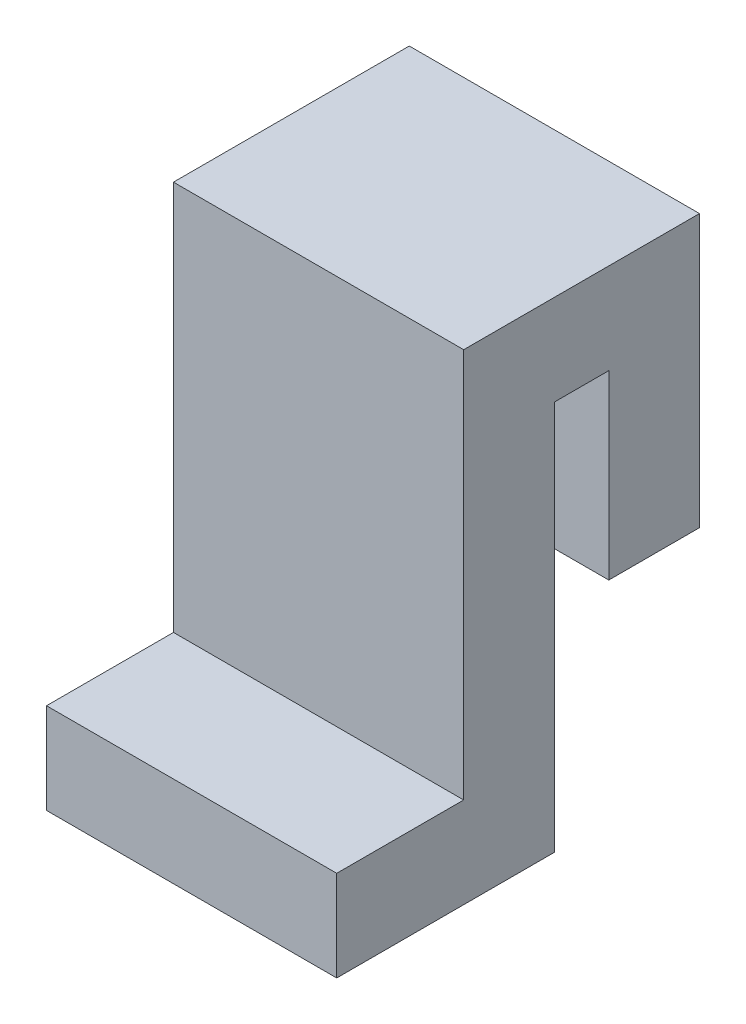
from build123d import *

# Parameters (mm, degrees)
BOSS_EXTRUDE1_DEPTH = 203.2


with BuildPart() as part:
    # Sketch1 → Boss-Extrude1 (new body, symmetric)
    with BuildSketch(Plane(origin=(0, 0, 0), x_dir=(0, 0, -1), z_dir=(1, 0, 0))):
        Polygon((-241.3, -273.05), (-63.5, -273.05), (-63.5, 273.05), (63.5, 273.05), (266.7, 273.05), (266.7, 146.05), (266.7, -107.95), (139.7, -107.95), (139.7, 146.05), (63.5, 146.05), (63.5, -273.05), (63.5, -400.05), (-241.3, -400.05), align=None)
    extrude(amount=BOSS_EXTRUDE1_DEPTH, both=True)


solid = part.part
